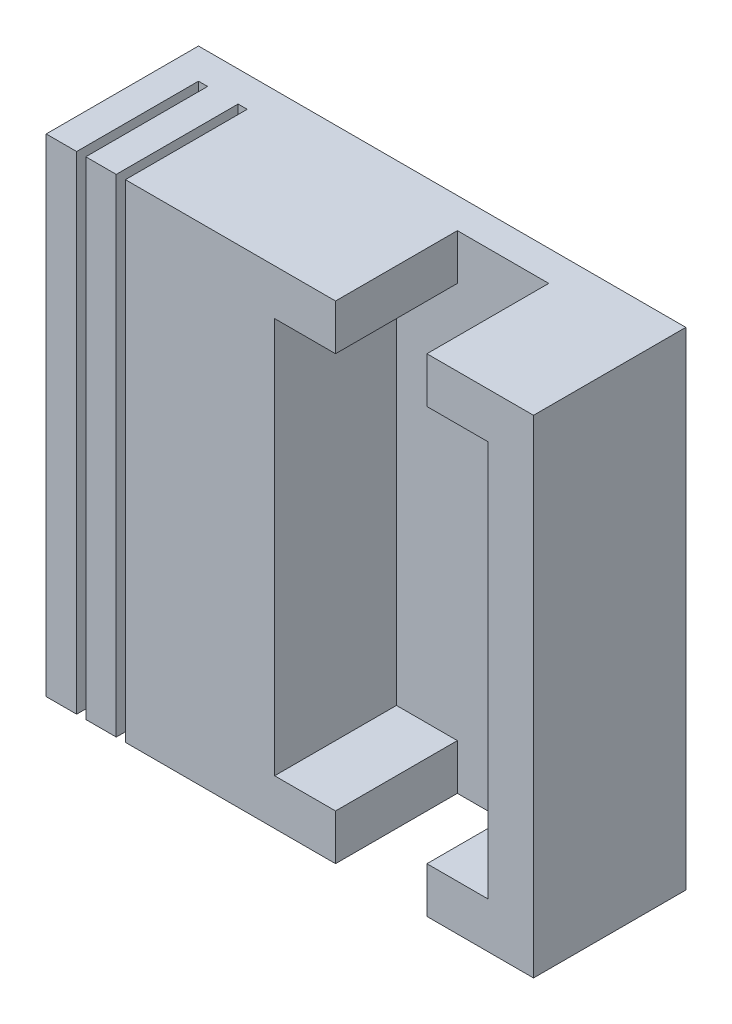
from build123d import *

# Parameters (mm, degrees)
SKETCH1_W           = 20.32
SKETCH1_H           = 20.32
BOSS_EXTRUDE1_DEPTH = 6.35
CUT_EXTRUDE1_DEPTH  = 5.08
SKETCH4_W           = 0.381
SKETCH4_H           = 21.648681081
CUT_EXTRUDE2_DEPTH  = 5.08


with BuildPart() as part:
    # Sketch1 → Boss-Extrude1 (new body)
    with BuildSketch(Plane(origin=(0, 0, 0), x_dir=(0, 1, 0), z_dir=(0, 0, 1))):
        with Locations((10.16, 10.16)):
            Rectangle(SKETCH1_W, SKETCH1_H)
    extrude(amount=BOSS_EXTRUDE1_DEPTH)

    # Sketch2 → Cut-Extrude1 (cut)
    with BuildSketch(Plane.XY.offset(6.35)):
        Polygon((-10.795, 18.415), (-8.255, 18.415), (-8.255, 20.32), (-4.445, 20.32), (-4.445, 18.415), (-1.905, 18.415), (-1.905, 1.905), (-4.445, 1.905), (-4.445, -0.532919187), (-8.255, -0.532919187), (-8.255, 1.905), (-10.795, 1.905), align=None)
    extrude(amount=-CUT_EXTRUDE1_DEPTH, mode=Mode.SUBTRACT)

    # Sketch4 → Cut-Extrude2 (cut)
    with BuildSketch(Plane.XY.offset(6.35)):
        with Locations((-18.8595, 9.956894273)):
            Rectangle(SKETCH4_W, SKETCH4_H)
        with Locations((-17.2085, 9.956894273)):
            Rectangle(SKETCH4_W, SKETCH4_H)
    extrude(amount=-CUT_EXTRUDE2_DEPTH, mode=Mode.SUBTRACT)


solid = part.part
